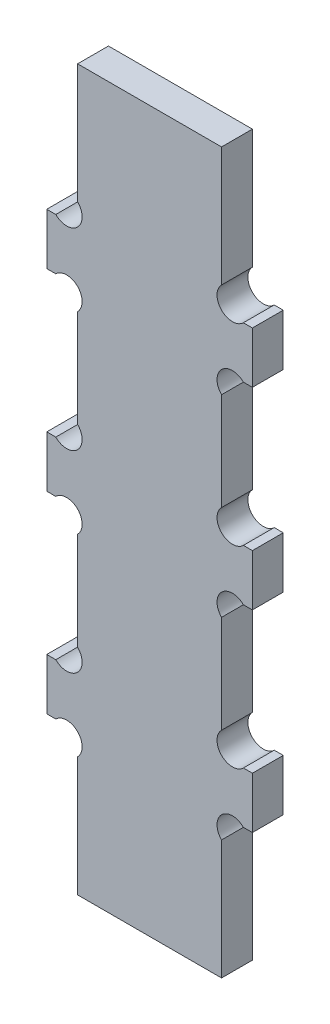
from build123d import *

# Parameters (mm, degrees)
CROQUIS1_W              = 20
CROQUIS1_H              = 70
SALIENTE_EXTRUIR1_DEPTH = 3
CROQUIS2_W              = 3
CROQUIS2_H              = 13.75
CORTAR_EXTRUIR1_DEPTH   = 4
CROQUIS3_R              = 1.5
CORTAR_EXTRUIR2_DEPTH   = 4


with BuildPart() as part:
    # Croquis1 → Saliente-Extruir1 (new body)
    with BuildSketch(Plane.XY):
        Rectangle(CROQUIS1_W, CROQUIS1_H)
    extrude(amount=SALIENTE_EXTRUIR1_DEPTH)

    # Croquis2 → Cortar-Extruir1 (cut, through all)
    with BuildSketch(Plane.XY.offset(3)):
        with Locations((8.5, 28.125)):
            Rectangle(CROQUIS2_W, CROQUIS2_H)
        with Locations((8.5, 9.375)):
            Rectangle(CROQUIS2_W, CROQUIS2_H)
        with Locations((8.5, -28.125)):
            Rectangle(CROQUIS2_W, CROQUIS2_H)
        with Locations((8.5, -9.375)):
            Rectangle(CROQUIS2_W, CROQUIS2_H)
        with Locations((-8.5, -9.375)):
            Rectangle(CROQUIS2_W, CROQUIS2_H)
        with Locations((-8.5, -28.125)):
            Rectangle(CROQUIS2_W, CROQUIS2_H)
        with Locations((-8.5, 9.375)):
            Rectangle(CROQUIS2_W, CROQUIS2_H)
        with Locations((-8.5, 28.125)):
            Rectangle(CROQUIS2_W, CROQUIS2_H)
    extrude(amount=-CORTAR_EXTRUIR1_DEPTH, mode=Mode.SUBTRACT)

    # Croquis3 → Cortar-Extruir2 (cut, through all)
    with BuildSketch(Plane.XY.offset(3)):
        with Locations((8.060660172, 22.310660172)):
            Circle(CROQUIS3_R)
        with Locations((8.060660172, 15.189339828)):
            Circle(CROQUIS3_R)
        with Locations((8.060660172, 3.560660172)):
            Circle(CROQUIS3_R)
        with Locations((8.060660172, -3.560660172)):
            Circle(CROQUIS3_R)
        with Locations((8.060660172, -15.189339828)):
            Circle(CROQUIS3_R)
        with Locations((8.060660172, -22.310660172)):
            Circle(CROQUIS3_R)
        with Locations((-8.060660172, -22.310660172)):
            Circle(CROQUIS3_R)
        with Locations((-8.060660172, -15.189339828)):
            Circle(CROQUIS3_R)
        with Locations((-8.060660172, -3.560660172)):
            Circle(CROQUIS3_R)
        with Locations((-8.060660172, 3.560660172)):
            Circle(CROQUIS3_R)
        with Locations((-8.060660172, 15.189339828)):
            Circle(CROQUIS3_R)
        with Locations((-8.060660172, 22.310660172)):
            Circle(CROQUIS3_R)
    extrude(amount=-CORTAR_EXTRUIR2_DEPTH, mode=Mode.SUBTRACT)


solid = part.part
